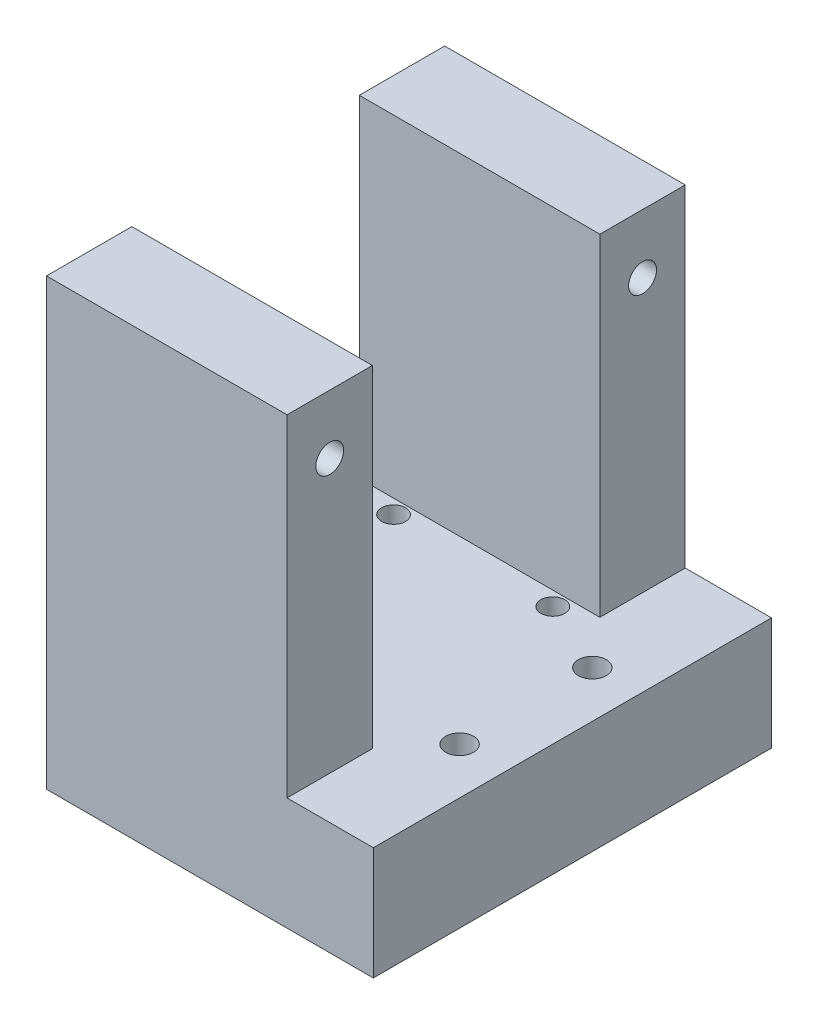
from build123d import *

# Parameters (mm, degrees)
CROQUIS1_R              = 1.8
CROQUIS1_R_2            = 2.1
SALIENTE_EXTRUIR4_DEPTH = 17
CROQUIS2_W              = 48.25
CROQUIS2_H              = 10
SALIENTE_EXTRUIR5_DEPTH = 17
CROQUIS3_W              = 36.25
CROQUIS3_H              = 12.86
SALIENTE_EXTRUIR6_DEPTH = 50
CROQUIS4_R              = 2.1
CORTAR_EXTRUIR1_DEPTH   = 50
CROQUIS5_W              = 60
CROQUIS5_H              = 17
SALIENTE_EXTRUIR7_DEPTH = 1


with BuildPart() as part:
    # Croquis1 → Saliente-Extruir4 (new body)
    with BuildSketch(Plane(origin=(0, 0, 0), x_dir=(1, 0, 0), z_dir=(0, 1, 0))):
        Polygon((0, 0), (48.11, 0), (48.25, 0), (48.25, 20), (48.25, 40), (48.11, 40), (0, 40), align=None)
        with Locations((7.3, 5)):
            Circle(CROQUIS1_R, mode=Mode.SUBTRACT)
        with Locations((31.3, 5)):
            Circle(CROQUIS1_R, mode=Mode.SUBTRACT)
        with Locations((31.3, 35)):
            Circle(CROQUIS1_R, mode=Mode.SUBTRACT)
        with Locations((7.3, 35)):
            Circle(CROQUIS1_R, mode=Mode.SUBTRACT)
        with Locations((42.25, 30)):
            Circle(CROQUIS1_R_2, mode=Mode.SUBTRACT)
        with Locations((42.25, 10)):
            Circle(CROQUIS1_R_2, mode=Mode.SUBTRACT)
    extrude(amount=SALIENTE_EXTRUIR4_DEPTH)

    # Croquis2 → Saliente-Extruir5 (add)
    with BuildSketch(Plane(origin=(0, 17, 0), x_dir=(1, 0, 0), z_dir=(0, 1, 0))):
        with Locations((24.125, 45)):
            Rectangle(CROQUIS2_W, CROQUIS2_H)
        with Locations((24.125, -5)):
            Rectangle(CROQUIS2_W, CROQUIS2_H)
    extrude(amount=-SALIENTE_EXTRUIR5_DEPTH)

    # Croquis3 → Saliente-Extruir6 (add)
    with BuildSketch(Plane(origin=(0, 17, 0), x_dir=(1, 0, 0), z_dir=(0, 1, 0))):
        with Locations((18.125, 43.57)):
            Rectangle(CROQUIS3_W, CROQUIS3_H)
        with Locations((18.125, -3.57)):
            Rectangle(CROQUIS3_W, CROQUIS3_H)
    extrude(amount=SALIENTE_EXTRUIR6_DEPTH)

    # Croquis4 → Cortar-Extruir1 (cut)
    with BuildSketch(Plane.ZY):
        with Locations((-43.57, 58.1)):
            Circle(CROQUIS4_R)
        with Locations((3.57, 58.1)):
            Circle(CROQUIS4_R)
    extrude(amount=-CORTAR_EXTRUIR1_DEPTH, mode=Mode.SUBTRACT)

    # Croquis5 → Saliente-Extruir7 (add)
    with BuildSketch(Plane(origin=(48.25, 0, 0), x_dir=(0, 0, -1), z_dir=(1, 0, 0))):
        with Locations((20, 8.5)):
            Rectangle(CROQUIS5_W, CROQUIS5_H)
    extrude(amount=SALIENTE_EXTRUIR7_DEPTH)


solid = part.part
